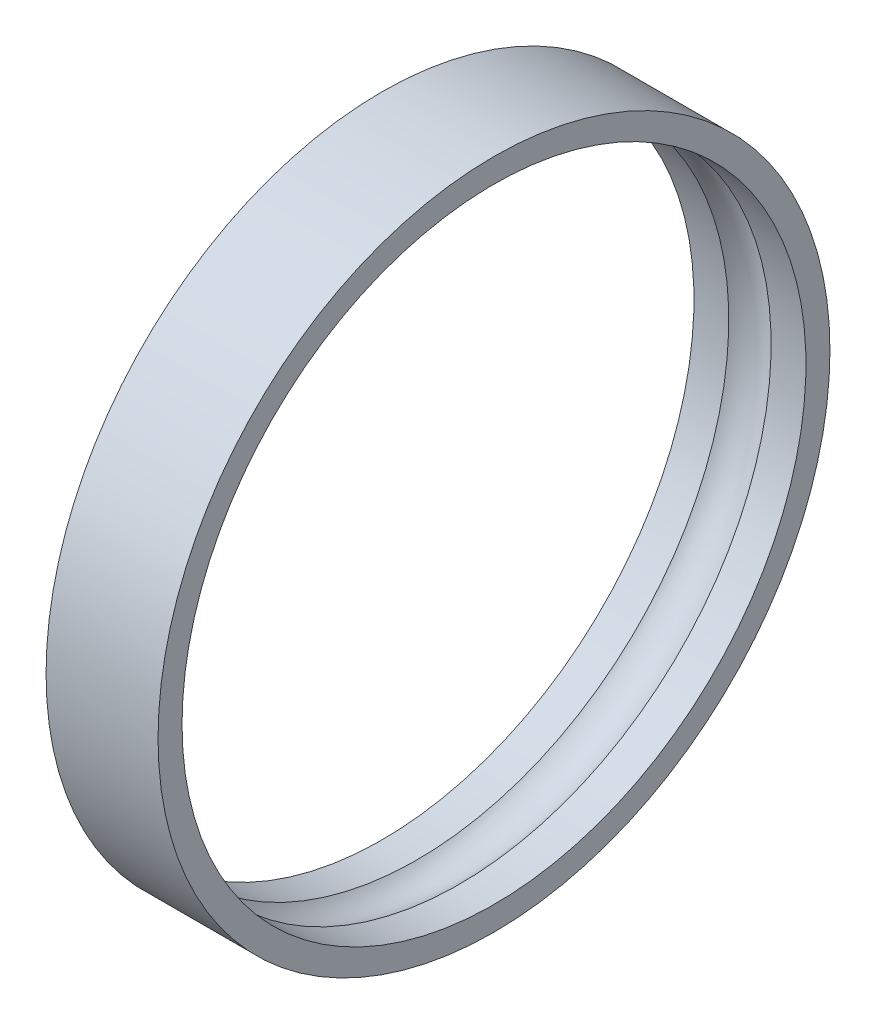
from build123d import *


with BuildPart() as part:
    # 草图1 → 旋转1 (revolve)
    with BuildSketch(Plane(origin=(0, 0, 0), x_dir=(1, 0, 0), z_dir=(0, 1, 0))):
        with BuildLine():
            Line((-3.5, -1.5), (-1.322875656, -1.5))
            ThreePointArc((-1.322875656, -1.5), (0, -2), (1.322875656, -1.5))
            Line((1.322875656, -1.5), (3.5, -1.5))
            Line((3.5, -1.5), (3.5, -3))
            Line((3.5, -3), (-3.5, -3))
            Line((-3.5, -3), (-3.5, -1.5))
        make_face()
    revolve(axis=Axis((0, 0, -18), (1, 0, 0)))


solid = part.part
